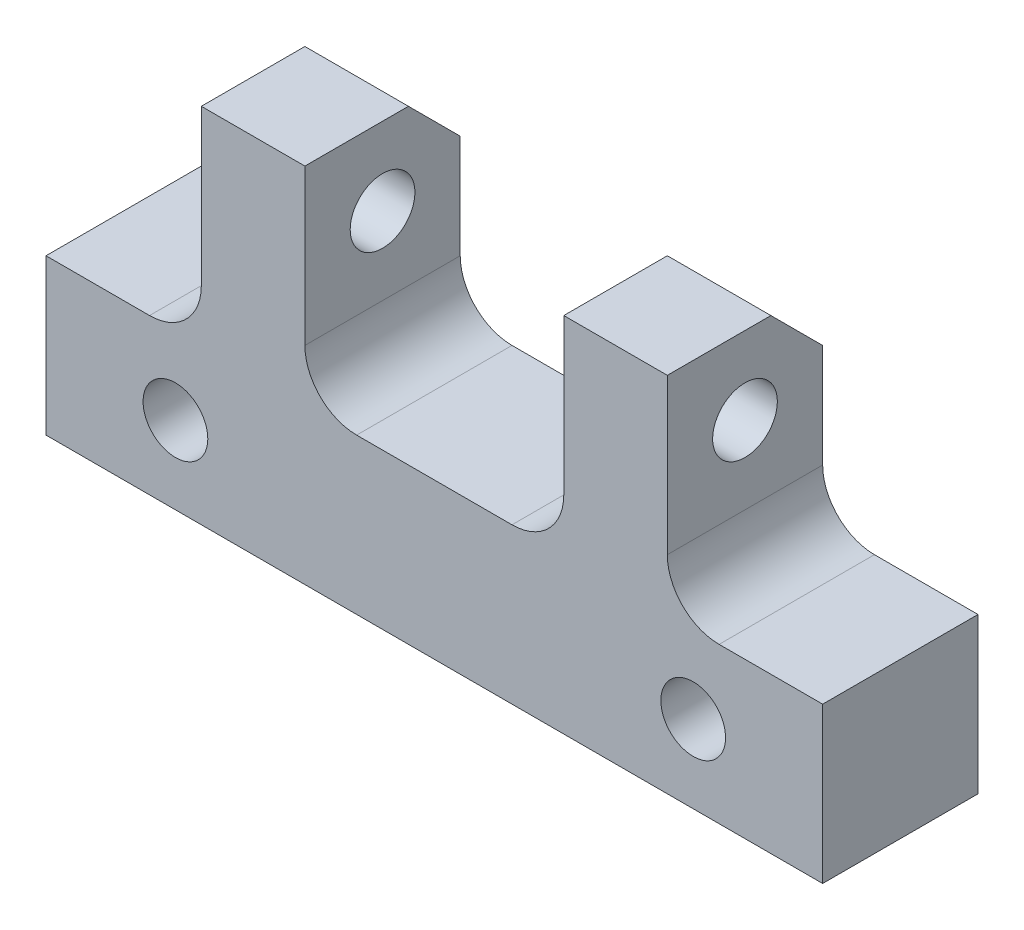
from build123d import *

# Parameters (mm, degrees)
SKETCH_1_R               = 1.25
EXTRUDE_1_DEPTH          = 6
CHAMFER_1_SIZE           = 2
SKETCH_2_R               = 1.25
CUT_EXTRUDE_1_DEPTH      = 16
CUT_EXTRUDE_1_DEPTH_BACK = 16
FILLET_1_R               = 2


with BuildPart() as part:
    # 草图1 → 凸台-拉伸1 (new body)
    with BuildSketch(Plane.XY):
        Polygon((-15, -6), (15, -6), (15, 0), (9, 0), (9, 8), (5, 8), (5, 0), (-5, 0), (-5, 8), (-9, 8), (-9, 0), (-15, 0), align=None)
        with Locations((-10, -3)):
            Circle(SKETCH_1_R, mode=Mode.SUBTRACT)
        with Locations((10, -3)):
            Circle(SKETCH_1_R, mode=Mode.SUBTRACT)
    extrude(amount=EXTRUDE_1_DEPTH)

    # 倒角1
    chamfer_1_edges = [part.edges().sort_by_distance(p)[0] for p in [
        (-7, 8, 0),
        (7, 8, 0),
    ]]
    chamfer(chamfer_1_edges, length=CHAMFER_1_SIZE)

    # 草图2 → 切除-拉伸1 (cut, two sides)
    with BuildSketch(Plane(origin=(0, 0, 0), x_dir=(0, 0, -1), z_dir=(1, 0, 0))) as cut_extrude_1_sk:
        with Locations((-3, 5)):
            Circle(SKETCH_2_R)
    extrude(amount=CUT_EXTRUDE_1_DEPTH, mode=Mode.SUBTRACT)
    extrude(cut_extrude_1_sk.sketch, amount=-CUT_EXTRUDE_1_DEPTH_BACK, mode=Mode.SUBTRACT)

    # 圆角1
    fillet_1_edges = [part.edges().sort_by_distance(p)[0] for p in [
        (-9, 0, 3),
        (-5, 0, 3),
        (5, 0, 3),
        (9, 0, 3),
    ]]
    fillet(fillet_1_edges, radius=FILLET_1_R)


solid = part.part
